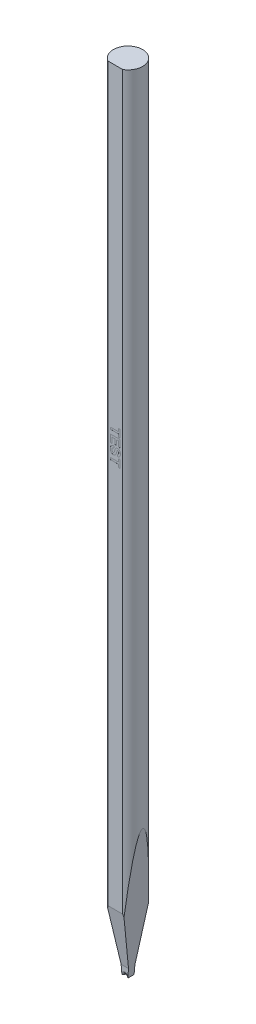
from build123d import *

# Parameters (mm, degrees)
SKETCH_TL_CUTTING_R       = 1.4986
TL_CUTTING_DEPTH          = 81.28
SKETCH_TDF_GRINDING_W     = 3.0172
SKETCH_TDF_GRINDING_H     = 3.0172
TDF_GRINDING_DEPTH        = 82.28
ENGRAVING_DEPTH           = 0.005
VW_VR_GRINDING_DEPTH      = 1.5086
VW_VR_GRINDING_DEPTH_BACK = 1.5086
ISA_GRINDING_DEPTH        = 1.5086
ISA_GRINDING_DEPTH_BACK   = 1.5086
SKETCH_PRE_FRX_BRX_W      = 1.18348
SKETCH_PRE_FRX_BRX_H      = 0.889
PRE_FRX_BRX_DEPTH         = 1.5086
PRE_FRX_BRX_DEPTH_BACK    = 1.5086
FR_EDM_R                  = 0.22606
BR_EDM_R                  = 0.22606
FA_BA_GRINDING_DEPTH      = 1.5086
FA_BA_GRINDING_DEPTH_BACK = 1.5086


with BuildPart() as part:
    # sketch_TL_cutting → TL_cutting (new body)
    with BuildSketch(Plane(origin=(0, 0, 0), x_dir=(1, 0, 0), z_dir=(0, 1, 0))):
        Circle(SKETCH_TL_CUTTING_R)
    extrude(amount=TL_CUTTING_DEPTH)

    # sketch_TDF_grinding → TDF_grinding (cut, through all)
    with BuildSketch(Plane(origin=(0, 0, 0), x_dir=(1, 0, 0), z_dir=(0, 1, 0))):
        with Locations((0, -2.804)):
            Rectangle(SKETCH_TDF_GRINDING_W, SKETCH_TDF_GRINDING_H)
    extrude(amount=TDF_GRINDING_DEPTH, mode=Mode.SUBTRACT)

    # sketch_engraving → engraving (cut)
    with BuildSketch(Plane.XY.offset(1.2954)):
        Polygon((-0.5, 48.946667), (0.333333, 48.946667), (0.333333, 49.241538), (0.5, 49.241538), (0.5, 48.459487), (0.333333, 48.459487), (0.333333, 48.754359), (-0.5, 48.754359), align=None)
        Polygon((-0.5, 48.331282), (0.5, 48.331282), (0.5, 47.587692), (0.333333, 47.587692), (0.333333, 48.138974), (0.115385, 48.138974), (0.115385, 47.626154), (-0.051282, 47.626154), (-0.051282, 48.138974), (-0.333333, 48.138974), (-0.333333, 47.574872), (-0.5, 47.574872), align=None)
        with BuildLine():
            Line((-0.166667, 47.459487), (-0.153846, 47.267179))
            add(Edge.make_bspline(
                [(-0.153846, 47.267179), (-0.161891, 47.265647), (-0.177518, 47.26267), (-0.199795, 47.256066), (-0.220542, 47.24876), (-0.239663, 47.240147), (-0.257106, 47.230282), (-0.273157, 47.219491), (-0.287328, 47.207249), (-0.299925, 47.193917), (-0.310783, 47.179344), (-0.320246, 47.163643), (-0.328256, 47.146722), (-0.334922, 47.128645), (-0.339885, 47.109231), (-0.34342, 47.088664), (-0.345683, 47.066909), (-0.345994, 47.052041), (-0.346154, 47.044423)],
                knots=[0, 0, 0, 0, 2.5e-05, 4.8e-05, 7e-05, 9.1e-05, 0.000111, 0.00013, 0.000148, 0.000167, 0.000185, 0.000203, 0.000221, 0.000241, 0.000261, 0.000281, 0.000303, 0.000326, 0.000326, 0.000326, 0.000326], degree=3))
            add(Edge.make_bspline(
                [(-0.346154, 47.044423), (-0.346066, 47.036405), (-0.345896, 47.020809), (-0.343785, 46.998208), (-0.340761, 46.977076), (-0.335974, 46.957598), (-0.330621, 46.939412), (-0.323297, 46.922967), (-0.314849, 46.907999), (-0.305264, 46.894547), (-0.294632, 46.882806), (-0.283534, 46.872535), (-0.272208, 46.86359), (-0.260151, 46.856549), (-0.247852, 46.850851), (-0.234944, 46.847085), (-0.221722, 46.844541), (-0.212686, 46.84425), (-0.208133, 46.844103)],
                knots=[0, 0, 0, 0, 2.4e-05, 4.7e-05, 6.8e-05, 8.8e-05, 0.000107, 0.000125, 0.000142, 0.000158, 0.000174, 0.000189, 0.000204, 0.000217, 0.000231, 0.000244, 0.000258, 0.000271, 0.000271, 0.000271, 0.000271], degree=3))
            add(Edge.make_bspline(
                [(-0.208133, 46.844103), (-0.202439, 46.844397), (-0.191321, 46.844971), (-0.175221, 46.848742), (-0.160659, 46.855546), (-0.147071, 46.864783), (-0.134927, 46.877747), (-0.12346, 46.894151), (-0.113169, 46.914611), (-0.107424, 46.92978), (-0.104367, 46.937853)],
                knots=[0, 0, 0, 0, 1.7e-05, 3.3e-05, 4.9e-05, 6.5e-05, 8.2e-05, 0.000102, 0.000125, 0.000151, 0.000151, 0.000151, 0.000151], degree=3))
            add(Edge.make_bspline(
                [(-0.104367, 46.937853), (-0.103206, 46.941317), (-0.100608, 46.949069), (-0.096897, 46.962295), (-0.092218, 46.97828), (-0.087053, 46.997174), (-0.081545, 47.018937), (-0.074956, 47.043362), (-0.068334, 47.070822), (-0.063456, 47.090035), (-0.060897, 47.100112)],
                knots=[0, 0, 0, 0, 1.1e-05, 2.5e-05, 4.1e-05, 6.1e-05, 8.3e-05, 0.000109, 0.000137, 0.000168, 0.000168, 0.000168, 0.000168], degree=3))
            add(Edge.make_bspline(
                [(-0.060897, 47.100112), (-0.057621, 47.113236), (-0.051299, 47.138555), (-0.040053, 47.174667), (-0.02888, 47.207927), (-0.016756, 47.238014), (-0.004503, 47.26526), (0.008738, 47.289226), (0.02228, 47.31041), (0.032402, 47.322754), (0.03726, 47.328678)],
                knots=[0, 0, 0, 0, 4.1e-05, 7.8e-05, 0.000113, 0.000146, 0.000176, 0.000203, 0.000228, 0.000251, 0.000251, 0.000251, 0.000251], degree=3))
            add(Edge.make_bspline(
                [(0.03726, 47.328678), (0.044138, 47.336024), (0.057623, 47.350427), (0.079781, 47.369385), (0.103188, 47.385316), (0.127671, 47.398429), (0.15337, 47.408525), (0.180114, 47.415681), (0.207972, 47.420313), (0.226945, 47.420786), (0.236579, 47.421026)],
                knots=[0, 0, 0, 0, 3e-05, 5.9e-05, 8.7e-05, 0.000115, 0.000142, 0.00017, 0.000198, 0.000227, 0.000227, 0.000227, 0.000227], degree=3))
            add(Edge.make_bspline(
                [(0.236579, 47.421026), (0.249045, 47.420558), (0.273774, 47.419631), (0.310123, 47.411129), (0.345194, 47.39788), (0.373053, 47.382528), (0.394102, 47.367749), (0.409316, 47.355523), (0.423235, 47.341833), (0.436363, 47.327171), (0.448421, 47.311292), (0.459337, 47.294176), (0.469762, 47.276144), (0.481724, 47.249832), (0.494502, 47.214301), (0.505217, 47.168066), (0.51162, 47.11772), (0.512411, 47.082771), (0.512821, 47.064655)],
                knots=[0, 0, 0, 0, 3.7e-05, 7.4e-05, 0.000111, 0.00015, 0.000169, 0.000188, 0.000208, 0.000228, 0.000247, 0.000268, 0.000288, 0.00031, 0.000354, 0.000402, 0.000452, 0.000506, 0.000506, 0.000506, 0.000506], degree=3))
            add(Edge.make_bspline(
                [(0.512821, 47.064655), (0.512623, 47.049822), (0.512239, 47.020972), (0.508327, 46.979155), (0.502301, 46.940146), (0.493472, 46.904011), (0.482081, 46.870682), (0.468308, 46.840093), (0.452029, 46.812325), (0.433078, 46.787673), (0.412189, 46.76571), (0.389372, 46.746551), (0.364915, 46.730122), (0.338835, 46.716318), (0.311, 46.705477), (0.281444, 46.697515), (0.250236, 46.692249), (0.228852, 46.690929), (0.217949, 46.690256)],
                knots=[0, 0, 0, 0, 4.4e-05, 8.7e-05, 0.000126, 0.000163, 0.000198, 0.000231, 0.000263, 0.000294, 0.000324, 0.000354, 0.000383, 0.000413, 0.000442, 0.000473, 0.000504, 0.000537, 0.000537, 0.000537, 0.000537], degree=3))
            Line((0.217949, 46.690256), (0.205128, 46.882564))
            add(Edge.make_bspline(
                [(0.205128, 46.882564), (0.211159, 46.883673), (0.222912, 46.885834), (0.23974, 46.890541), (0.255319, 46.895822), (0.26955, 46.902088), (0.282453, 46.909307), (0.294054, 46.917511), (0.304443, 46.926547), (0.313349, 46.936795), (0.321255, 46.948019), (0.32777, 46.960646), (0.333733, 46.974284), (0.338229, 46.989445), (0.341792, 47.005854), (0.344434, 47.023515), (0.345724, 47.042468), (0.346007, 47.055506), (0.346154, 47.062252)],
                knots=[0, 0, 0, 0, 1.8e-05, 3.6e-05, 5.2e-05, 6.8e-05, 8.2e-05, 9.7e-05, 0.00011, 0.000124, 0.000137, 0.000151, 0.000166, 0.000182, 0.000199, 0.000217, 0.000235, 0.000256, 0.000256, 0.000256, 0.000256], degree=3))
            add(Edge.make_bspline(
                [(0.346154, 47.062252), (0.346025, 47.069265), (0.345773, 47.082911), (0.344229, 47.102795), (0.341378, 47.121449), (0.337667, 47.138963), (0.332619, 47.155313), (0.326463, 47.170466), (0.319216, 47.184491), (0.313514, 47.193042), (0.310697, 47.197268)],
                knots=[0, 0, 0, 0, 2.1e-05, 4.1e-05, 6e-05, 7.8e-05, 9.5e-05, 0.000111, 0.000127, 0.000142, 0.000142, 0.000142, 0.000142], degree=3))
            add(Edge.make_bspline(
                [(0.310697, 47.197268), (0.306849, 47.202103), (0.299396, 47.211468), (0.284597, 47.221546), (0.267882, 47.227613), (0.256061, 47.228343), (0.25, 47.228718)],
                knots=[0, 0, 0, 0, 1.8e-05, 3.6e-05, 5.3e-05, 7.1e-05, 7.1e-05, 7.1e-05, 7.1e-05], degree=3))
            add(Edge.make_bspline(
                [(0.25, 47.228718), (0.244335, 47.228412), (0.233176, 47.227808), (0.217325, 47.221724), (0.202638, 47.212366), (0.19466, 47.203623), (0.190505, 47.199071)],
                knots=[0, 0, 0, 0, 1.7e-05, 3.3e-05, 5e-05, 6.9e-05, 6.9e-05, 6.9e-05, 6.9e-05], degree=3))
            add(Edge.make_bspline(
                [(0.190505, 47.199071), (0.187808, 47.195457), (0.181782, 47.187383), (0.174123, 47.172593), (0.165827, 47.15474), (0.157718, 47.133419), (0.149623, 47.10877), (0.141171, 47.080793), (0.132606, 47.04947), (0.124311, 47.015599), (0.116157, 46.98121), (0.107243, 46.948394), (0.098552, 46.91788), (0.089443, 46.889809), (0.080575, 46.864037), (0.071467, 46.840688), (0.062597, 46.819604), (0.0504, 46.795016), (0.033879, 46.767149), (0.009862, 46.737941), (-0.017134, 46.71211), (-0.042589, 46.694112), (-0.064481, 46.681748), (-0.081932, 46.673787), (-0.100321, 46.6669), (-0.119668, 46.661294), (-0.14, 46.657231), (-0.161163, 46.653869), (-0.183331, 46.652151), (-0.198448, 46.651915), (-0.20613, 46.651795)],
                knots=[0, 0, 0, 0, 1.4e-05, 3e-05, 5e-05, 7.3e-05, 9.9e-05, 0.000128, 0.00016, 0.000196, 0.000232, 0.000266, 0.000298, 0.000327, 0.000355, 0.00038, 0.000403, 0.000423, 0.000462, 0.000499, 0.000536, 0.000574, 0.000593, 0.000612, 0.000631, 0.000652, 0.000672, 0.000693, 0.000716, 0.000739, 0.000739, 0.000739, 0.000739], degree=3))
            add(Edge.make_bspline(
                [(-0.20613, 46.651795), (-0.213214, 46.65196), (-0.227282, 46.652288), (-0.248162, 46.654578), (-0.268672, 46.65812), (-0.288836, 46.663363), (-0.308616, 46.670318), (-0.328297, 46.67815), (-0.347449, 46.687942), (-0.366088, 46.699088), (-0.384202, 46.711381), (-0.400907, 46.725314), (-0.416781, 46.740056), (-0.43083, 46.756561), (-0.4445, 46.773644), (-0.456414, 46.79242), (-0.467267, 46.812289), (-0.476944, 46.833431), (-0.485241, 46.855916), (-0.49276, 46.87961), (-0.498862, 46.904735), (-0.504103, 46.931122), (-0.508085, 46.958873), (-0.510867, 46.987951), (-0.512435, 47.018364), (-0.51269, 47.039079), (-0.512821, 47.049631)],
                knots=[0, 0, 0, 0, 2.1e-05, 4.2e-05, 6.3e-05, 8.4e-05, 0.000105, 0.000126, 0.000147, 0.000169, 0.000191, 0.000213, 0.000234, 0.000256, 0.000278, 0.0003, 0.000322, 0.000346, 0.00037, 0.000394, 0.00042, 0.000447, 0.000475, 0.000504, 0.000535, 0.000566, 0.000566, 0.000566, 0.000566], degree=3))
            add(Edge.make_bspline(
                [(-0.512821, 47.049631), (-0.512572, 47.064867), (-0.512087, 47.094531), (-0.507753, 47.137627), (-0.501118, 47.178048), (-0.491488, 47.215728), (-0.479126, 47.250714), (-0.463898, 47.28299), (-0.445714, 47.312398), (-0.425016, 47.339307), (-0.401421, 47.363346), (-0.375438, 47.384992), (-0.346734, 47.403825), (-0.315677, 47.420355), (-0.28186, 47.433843), (-0.24584, 47.445371), (-0.207126, 47.453948), (-0.180386, 47.457609), (-0.166667, 47.459487)],
                knots=[0, 0, 0, 0, 4.6e-05, 8.9e-05, 0.00013, 0.000168, 0.000205, 0.000241, 0.000275, 0.000309, 0.000343, 0.000376, 0.00041, 0.000445, 0.000482, 0.000519, 0.000559, 0.0006, 0.0006, 0.0006, 0.0006], degree=3))
        make_face()
        Polygon((-0.5, 46.254359), (0.333333, 46.254359), (0.333333, 46.549231), (0.5, 46.549231), (0.5, 45.767179), (0.333333, 45.767179), (0.333333, 46.062051), (-0.5, 46.062051), align=None)
    extrude(amount=-ENGRAVING_DEPTH, mode=Mode.SUBTRACT)

    # sketch_VW_VR_grinding → VW_VR_grinding (cut, two sides)
    with BuildSketch(Plane.XY) as vw_vr_grinding_sk:
        with BuildLine():
            Line((-1.4936, -0.01), (-1.4936, 0.874))
            ThreePointArc((-1.4936, 0.874), (-1.495064, 0.877536), (-1.4986, 0.879))
            Line((-1.4986, 0.879), (-1.5086, 0.879))
            Line((-1.5086, 0.879), (-1.5086, -0.01))
            Line((-1.5086, -0.01), (-1.4936, -0.01))
        make_face()
        with BuildLine():
            Line((1.4936, -0.01), (1.4936, 0.874))
            ThreePointArc((1.4936, 0.874), (1.495064, 0.877536), (1.4986, 0.879))
            Line((1.4986, 0.879), (1.5086, 0.879))
            Line((1.5086, 0.879), (1.5086, -0.01))
            Line((1.5086, -0.01), (1.4936, -0.01))
        make_face()
    extrude(amount=VW_VR_GRINDING_DEPTH, mode=Mode.SUBTRACT)
    extrude(vw_vr_grinding_sk.sketch, amount=-VW_VR_GRINDING_DEPTH_BACK, mode=Mode.SUBTRACT)

    # sketch_ISA_grinding → ISA_grinding (cut, two sides)
    with BuildSketch(Plane.XY) as isa_grinding_sk:
        Polygon((-0.29972, 0), (-1.5086, 13.817562), (-1.5086, -0.01), (1.5086, -0.01), (1.5086, 13.817562), (0.29972, 0), align=None)
    extrude(amount=ISA_GRINDING_DEPTH, mode=Mode.SUBTRACT)
    extrude(isa_grinding_sk.sketch, amount=-ISA_GRINDING_DEPTH_BACK, mode=Mode.SUBTRACT)

    # sketch_pre_FRX_BRX → pre_FRX_BRX (cut, two sides)
    with BuildSketch(Plane(origin=(0, 0, 0), x_dir=(0, 0, -1), z_dir=(1, 0, 0))) as pre_frx_brx_sk:
        with Locations((-0.91686, 0.4345)):
            Rectangle(SKETCH_PRE_FRX_BRX_W, SKETCH_PRE_FRX_BRX_H)
        with Locations((0.91686, 0.4345)):
            Rectangle(SKETCH_PRE_FRX_BRX_W, SKETCH_PRE_FRX_BRX_H)
    extrude(amount=PRE_FRX_BRX_DEPTH, mode=Mode.SUBTRACT)
    extrude(pre_frx_brx_sk.sketch, amount=-PRE_FRX_BRX_DEPTH_BACK, mode=Mode.SUBTRACT)

    # V-Groove_EDM: sweep along a path in sketch_contour_V-Groove
    with BuildLine(Plane(origin=(0, 0, 0), x_dir=(0, 0, -1), z_dir=(1, 0, 0))) as v_groove_edm_path:
        Line((-1.2954, 0.1905), (0, 0.1905))
        Line((0, 0.1905), (1.4986, 0.1905))
    # sketch_section_V-Groove → V-Groove_EDM (sweep, cut)
    with BuildSketch(Plane.XY.offset(1.2954)):
        with BuildLine():
            Line((-1.498995, -1.905), (-0.049899, 0.164524))
            ThreePointArc((-0.049899, 0.164524), (0, 0.1905), (0.049899, 0.164524))
            Line((0.049899, 0.164524), (1.498995, -1.905))
            Line((1.498995, -1.905), (-1.498995, -1.905))
        make_face()
    sweep(path=v_groove_edm_path.line, mode=Mode.SUBTRACT)

    # FR_EDM
    fr_edm_edges = [part.edges().sort_by_distance(p)[0] for p in [
        (0.107499, 0.082262, 0.32512),
        (0, 0.1905, 0.32512),
        (-0.107499, 0.082262, 0.32512),
    ]]
    fillet(fr_edm_edges, radius=FR_EDM_R)

    # BR_EDM
    br_edm_edges = [part.edges().sort_by_distance(p)[0] for p in [
        (0.107499, 0.082262, -0.32512),
        (0, 0.1905, -0.32512),
        (-0.107499, 0.082262, -0.32512),
    ]]
    fillet(br_edm_edges, radius=BR_EDM_R)

    # sketch_FA_BA_grinding → FA_BA_grinding (cut, two sides)
    with BuildSketch(Plane(origin=(0, 0, 0), x_dir=(0, 0, -1), z_dir=(1, 0, 0))) as fa_ba_grinding_sk:
        Polygon((2.4986, 13.215418), (2.4986, -0.1), (0.32512, -0.1), (0.32512, 0.889), align=None)
        Polygon((-4.003016, 21.747387), (-0.32512, 0.889), (-0.32512, -0.1), (-4.003016, -0.1), align=None)
    extrude(amount=FA_BA_GRINDING_DEPTH, mode=Mode.SUBTRACT)
    extrude(fa_ba_grinding_sk.sketch, amount=-FA_BA_GRINDING_DEPTH_BACK, mode=Mode.SUBTRACT)


solid = part.part
